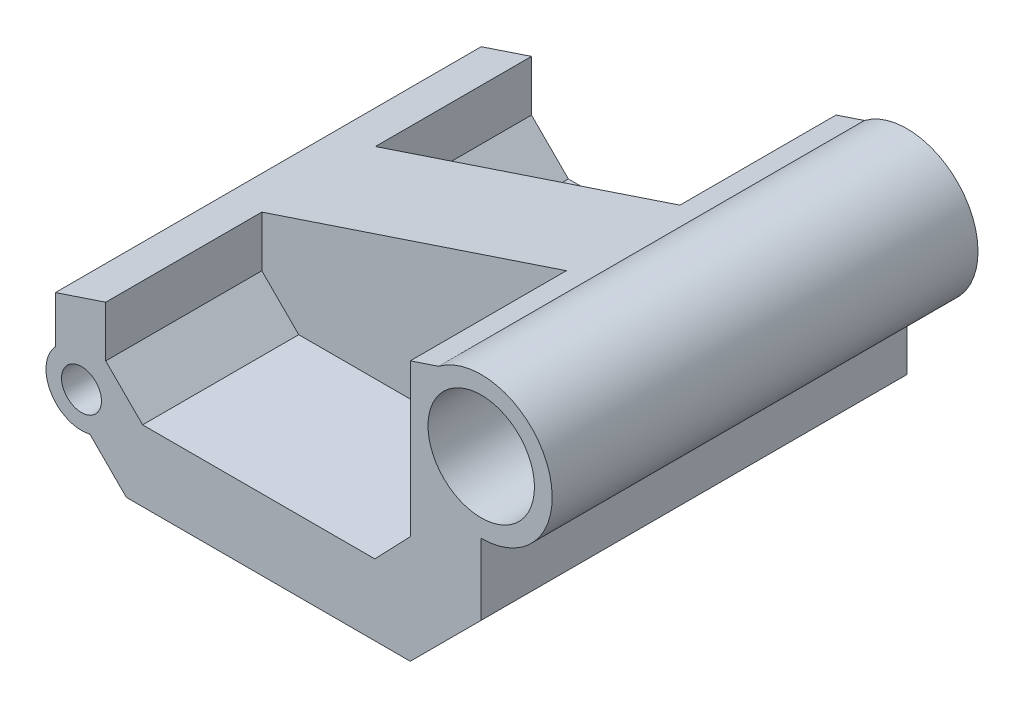
from build123d import *

# Parameters (mm, degrees)
BOSS_EXTRUDE1_DEPTH             = 19.05
BOSS_EXTRUDE1_DEPTH_BACK        = 19.05
SKETCH5_R                       = 6.35
BOSS_EXTRUDE2_DEPTH             = 38.1
F_3_8_0_375_DIAMETER_HOLE1_D    = 9.525
CUT_EXTRUDE2_DEPTH              = 38.1
CUT_EXTRUDE5_DEPTH              = 13.97
CUT_EXTRUDE6_DEPTH              = 13.97
CUT_EXTRUDE7_DEPTH              = 39.1
BOSS_EXTRUDE5_DEPTH             = 38.1
BOSS_EXTRUDE6_DEPTH             = 38.1
F_9_64_0_14063_DIAMETER_HOLE2_D = 3.572002
SKETCH25_R                      = 3.302
CUT_EXTRUDE8_DEPTH              = 12.7
CUT_EXTRUDE8_DEPTH_BACK         = 12.7
SKETCH28_W                      = 2.54
SKETCH28_H                      = 4.012120109
CUT_EXTRUDE9_DEPTH              = 4.499728


with BuildPart() as part:
    # Sketch4 → Boss-Extrude1 (new body, two sides)
    with BuildSketch(Plane.XY) as boss_extrude1_sk:
        Polygon((25.4, 1.404612262), (25.4, 14.104612262), (63.5, 26.804612262), (63.5, 1.404612262), align=None)
    extrude(amount=BOSS_EXTRUDE1_DEPTH)
    extrude(boss_extrude1_sk.sketch, amount=-BOSS_EXTRUDE1_DEPTH_BACK)

    # Sketch5 → Boss-Extrude2 (add)
    with BuildSketch(Plane.XY.offset(19.05)):
        with Locations((63.5, 20.454612262)):
            Circle(SKETCH5_R)
    extrude(amount=-BOSS_EXTRUDE2_DEPTH)

    # 3_8 _0.375_ Diameter Hole1 (through all)
    with Locations(Plane.XY.offset(19.05)):
        with Locations((63.5, 20.454612262)):
            Hole(F_3_8_0_375_DIAMETER_HOLE1_D / 2)

    # Sketch11 → Cut-Extrude2 (cut)
    with BuildSketch(Plane.XY.offset(19.05)):
        Polygon((63.5, 7.754612262), (57.15, 1.404612262), (63.5, 1.404612262), align=None)
    extrude(amount=-CUT_EXTRUDE2_DEPTH, mode=Mode.SUBTRACT)

    # Sketch20 → Cut-Extrude5 (cut)
    with BuildSketch(Plane.XY.offset(19.05)):
        Polygon((29.899727951, 7.754612262), (53.975, 7.754612262), (57.15, 11.056612262), (57.15, 24.687945595), (29.899727951, 15.604521579), align=None)
    extrude(amount=-CUT_EXTRUDE5_DEPTH, mode=Mode.SUBTRACT)

    # Sketch21 → Cut-Extrude6 (cut)
    with BuildSketch(Plane(origin=(0, 0, -19.05), x_dir=(-1, 0, 0), z_dir=(0, 0, -1))):
        Polygon((-57.15, 24.687945595), (-57.15, 11.056612262), (-53.975, 7.754612262), (-29.899727951, 7.754612262), (-29.899727951, 15.604521579), align=None)
    extrude(amount=-CUT_EXTRUDE6_DEPTH, mode=Mode.SUBTRACT)

    # Sketch11_4 → Cut-Extrude7 (cut, through all)
    with BuildSketch(Plane.XY.offset(19.05)):
        Polygon((25.4, 7.754612262), (31.75, 1.404612262), (25.4, 1.404612262), align=None)
    extrude(amount=-CUT_EXTRUDE7_DEPTH, mode=Mode.SUBTRACT)

    # Sketch22 → Boss-Extrude5 (add)
    with BuildSketch(Plane.XY.offset(19.05)):
        Polygon((33.201727951, 7.754612262), (29.899727951, 11.056612262), (29.899727951, 7.754612262), align=None)
    extrude(amount=-BOSS_EXTRUDE5_DEPTH)

    # Sketch23 → Boss-Extrude6 (add)
    with BuildSketch(Plane.XY.offset(19.05)):
        with BuildLine():
            ThreePointArc((28.484500237, 4.670112024), (30.228876772, 5.793622896), (30.906849398, 7.754612262))
            ThreePointArc((30.906849398, 7.754612262), (28.888785689, 10.711320469), (25.4, 9.909398419))
            Line((25.4, 9.909398419), (25.4, 7.754612262))
            Line((25.4, 7.754612262), (28.484500237, 4.670112024))
        make_face()
        with BuildLine():
            Line((25.4, 7.754612262), (25.4, 9.909398419))
            ThreePointArc((25.4, 9.909398419), (24.9957943, 6.143827516), (28.484500237, 4.670112024))
            Line((28.484500237, 4.670112024), (25.4, 7.754612262))
        make_face()
    extrude(amount=-BOSS_EXTRUDE6_DEPTH)

    # 9_64 _0.14063_ Diameter Hole2 (through all)
    with Locations(Plane(origin=(27.731849398, 7.754612262, 19.05), x_dir=(1, 0, 0), z_dir=(0, 0, 1))):
        with Locations((0, 0)):
            Hole(F_9_64_0_14063_DIAMETER_HOLE2_D / 2)

    # Sketch25 → Cut-Extrude8 (cut, two sides)
    with BuildSketch(Plane.XY) as cut_extrude8_sk:
        with Locations((27.731849398, 7.754612262)):
            Circle(SKETCH25_R)
    extrude(amount=CUT_EXTRUDE8_DEPTH, mode=Mode.SUBTRACT)
    extrude(cut_extrude8_sk.sketch, amount=-CUT_EXTRUDE8_DEPTH_BACK, mode=Mode.SUBTRACT)

    # Sketch28 → Cut-Extrude9 (cut)
    with BuildSketch(Plane.ZY.offset(-25.4)):
        with Locations((0, 12.098552208)):
            Rectangle(SKETCH28_W, SKETCH28_H)
    extrude(amount=-CUT_EXTRUDE9_DEPTH, mode=Mode.SUBTRACT)


solid = part.part
